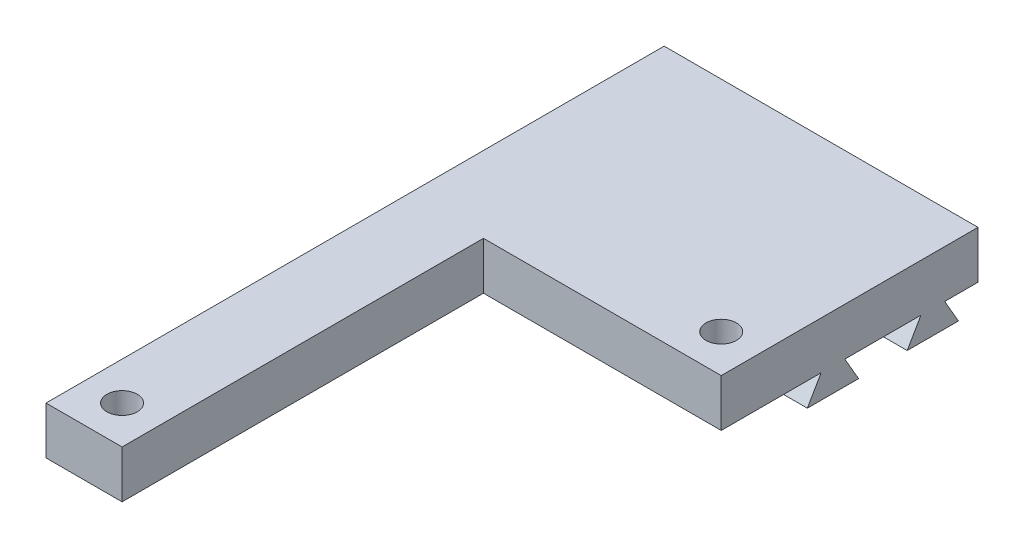
from build123d import *

# Parameters (mm, degrees)
BOSS_EXTRUDE1_DEPTH = 5
BOSS_EXTRUDE3_DEPTH = 33
SKETCH4_W           = 25
SKETCH4_H           = 5
BOSS_EXTRUDE4_DEPTH = 7
SKETCH5_W           = 8
SKETCH5_H           = 5
BOSS_EXTRUDE5_DEPTH = 5
SKETCH6_R           = 1.6
CUT_EXTRUDE1_DEPTH  = 5


with BuildPart() as part:
    # Sketch1 → Boss-Extrude1 (new body)
    with BuildSketch(Plane(origin=(0, 0, 0), x_dir=(1, 0, 0), z_dir=(0, 1, 0))):
        Polygon((-8.5, 10), (-8.5, -30), (-16.5, -30), (-16.5, 30), (16.5, 30), (16.5, 10), align=None)
    extrude(amount=BOSS_EXTRUDE1_DEPTH)

    # Sketch3 → Boss-Extrude3 (add)
    with BuildSketch(Plane(origin=(16.5, 0, 0), x_dir=(0, 0, -1), z_dir=(1, 0, 0))):
        Polygon((17.443375673, -2.5), (16, 0), (13.5, 0), (12.056624327, -2.5), align=None)
        Polygon((22.556624327, -2.5), (27.943375673, -2.5), (26.5, 0), (24, 0), align=None)
    extrude(amount=-BOSS_EXTRUDE3_DEPTH)

    # Sketch4 → Boss-Extrude4 (add)
    with BuildSketch(Plane.XY.offset(-10)):
        with Locations((4, 2.5)):
            Rectangle(SKETCH4_W, SKETCH4_H)
    extrude(amount=BOSS_EXTRUDE4_DEPTH)

    # Sketch5 → Boss-Extrude5 (add)
    with BuildSketch(Plane.XY.offset(30)):
        with Locations((-12.5, 2.5)):
            Rectangle(SKETCH5_W, SKETCH5_H)
    extrude(amount=BOSS_EXTRUDE5_DEPTH)

    # Sketch6 → Cut-Extrude1 (cut)
    with BuildSketch(Plane(origin=(0, 5, 0), x_dir=(1, 0, 0), z_dir=(0, 1, 0))):
        with Locations((12.5, 7)):
            Circle(SKETCH6_R)
        with Locations((-12.5, -31)):
            Circle(SKETCH6_R)
    extrude(amount=-CUT_EXTRUDE1_DEPTH, mode=Mode.SUBTRACT)


solid = part.part
